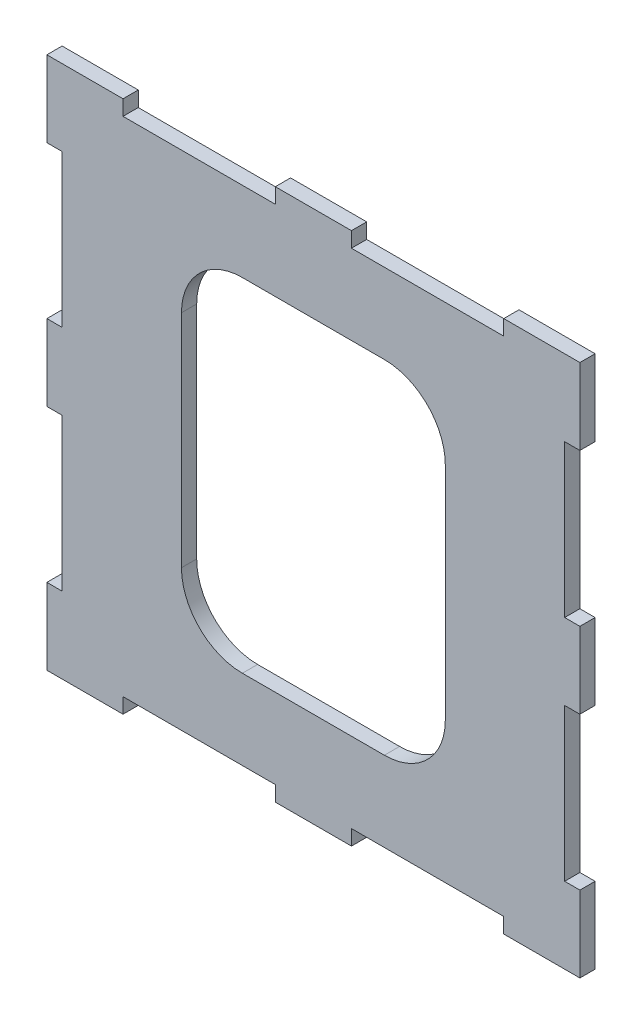
from build123d import *

# Parameters (mm, degrees)
SKETCH1_W           = 70
SKETCH1_H           = 70
BOSS_EXTRUDE1_DEPTH = 2
SKETCH2_W           = 2
SKETCH2_H           = 20
SKETCH2_W_2         = 20
SKETCH2_H_2         = 2
CUT_EXTRUDE1_DEPTH  = 2
CUT_EXTRUDE2_DEPTH  = 10


with BuildPart() as part:
    # Sketch1 → Boss-Extrude1 (new body)
    with BuildSketch(Plane.XY):
        Rectangle(SKETCH1_W, SKETCH1_H)
    extrude(amount=-BOSS_EXTRUDE1_DEPTH)

    # Sketch2 → Cut-Extrude1 (cut)
    with BuildSketch(Plane.XY):
        with Locations((-34, 15)):
            Rectangle(SKETCH2_W, SKETCH2_H)
        with Locations((-34, -15)):
            Rectangle(SKETCH2_W, SKETCH2_H)
        with Locations((-15, -34)):
            Rectangle(SKETCH2_W_2, SKETCH2_H_2)
        with Locations((15, -34)):
            Rectangle(SKETCH2_W_2, SKETCH2_H_2)
        with Locations((34, -15)):
            Rectangle(SKETCH2_W, SKETCH2_H)
        with Locations((34, 15)):
            Rectangle(SKETCH2_W, SKETCH2_H)
        with Locations((15, 34)):
            Rectangle(SKETCH2_W_2, SKETCH2_H_2)
        with Locations((-15, 34)):
            Rectangle(SKETCH2_W_2, SKETCH2_H_2)
    extrude(amount=-CUT_EXTRUDE1_DEPTH, mode=Mode.SUBTRACT)

    # Sketch6 → Cut-Extrude2 (cut)
    with BuildSketch(Plane(origin=(0, 0, -2), x_dir=(-1, 0, 0), z_dir=(0, 0, -1))):
        Polygon((-9.325, -14.5), (-9.325, -22.5), (9.325, -22.5), (9.325, -14.5), (17.325, -14.5), (17.325, 14.5), (9.325, 14.5), (9.325, 22.5), (-9.325, 22.5), (-9.325, 14.5), (-17.325, 14.5), (-17.325, -14.5), align=None)
        with BuildLine():
            Line((-9.325, 22.5), (-9.325, 14.5))
            Line((-9.325, 14.5), (-17.325, 14.5))
            ThreePointArc((-17.325, 14.5), (-14.981854249, 20.156854249), (-9.325, 22.5))
        make_face()
        with BuildLine():
            ThreePointArc((9.325, 22.5), (14.981854249, 20.156854249), (17.325, 14.5))
            Line((17.325, 14.5), (9.325, 14.5))
            Line((9.325, 14.5), (9.325, 22.5))
        make_face()
        with BuildLine():
            ThreePointArc((-9.325, -22.5), (-14.981854249, -20.156854249), (-17.325, -14.5))
            Line((-17.325, -14.5), (-9.325, -14.5))
            Line((-9.325, -14.5), (-9.325, -22.5))
        make_face()
        with BuildLine():
            Line((9.325, -22.5), (9.325, -14.5))
            Line((9.325, -14.5), (17.325, -14.5))
            ThreePointArc((17.325, -14.5), (14.981854249, -20.156854249), (9.325, -22.5))
        make_face()
    extrude(amount=-CUT_EXTRUDE2_DEPTH, mode=Mode.SUBTRACT)


solid = part.part
